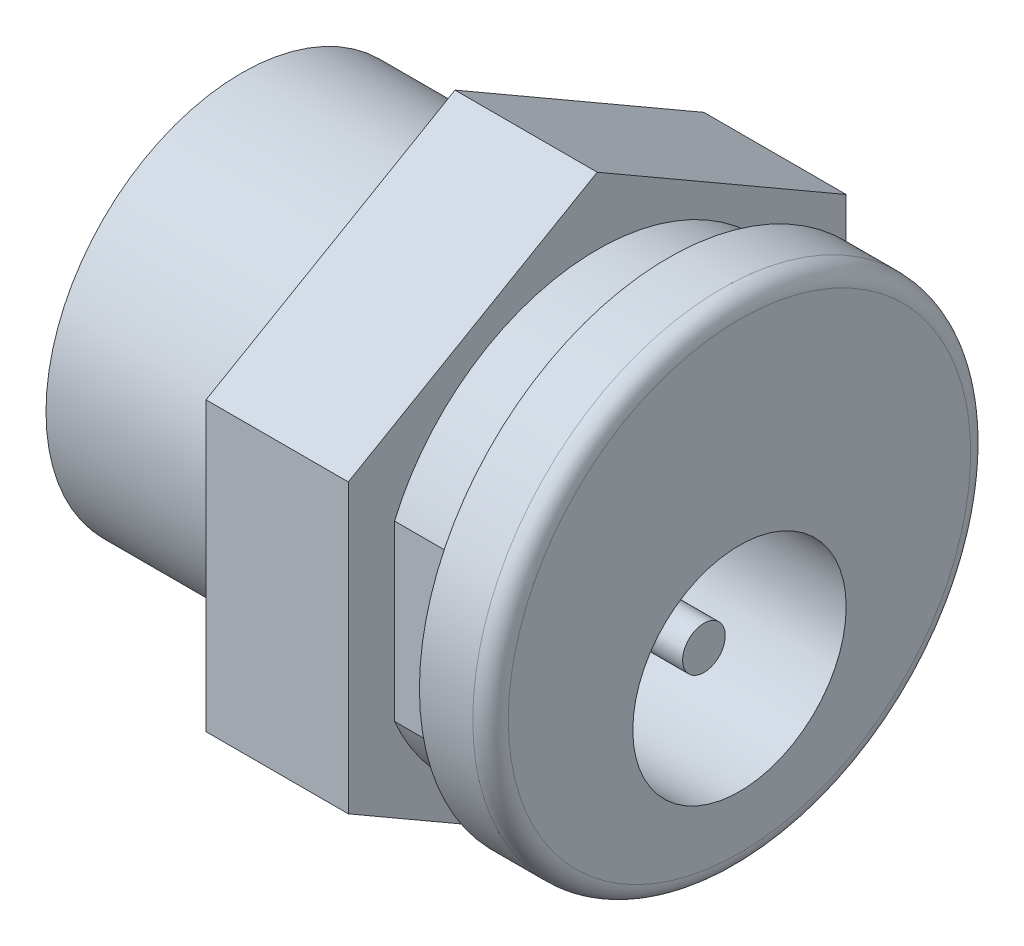
from build123d import *

# Parameters (mm, degrees)
ESQUISSE2_R             = 10
ENL_V_MAT_EXTRU_1_DEPTH = 4
ESQUISSE3_R             = 3
ESQUISSE3_R_2           = 0.6
ENL_V_MAT_EXTRU_2_DEPTH = 9
ESQUISSE4_R             = 0.6
ENL_V_MAT_EXTRU_3_DEPTH = 1
ENL_V_MAT_EXTRU_5_DEPTH = 2
CONG_1_R                = 0.5


with BuildPart() as part:
    # Esquisse1 → Révolution1 (revolve)
    with BuildSketch(Plane.XY, mode=Mode.PRIVATE) as r_volution1_sk:
        Polygon((0, 0), (0, 7), (-2, 7), (-2, 6.2), (-4, 6.2), (-4, 10), (-8, 10), (-8, 5.5), (-14, 5.5), (-14, 0), align=None)
    revolve(r_volution1_sk.sketch.rotate(Axis((0, 0, 0), (1, 0, 0)), 90), axis=Axis((0, 0, 0), (1, 0, 0)))  # turned: the seam where the file's is

    # Esquisse2 → Enlèv. mat.-Extru.1 (cut)
    with BuildSketch(Plane.ZY.offset(8)):
        Circle(ESQUISSE2_R)
        Polygon((0, 8.082903769), (-7, 4.041451884), (-7, -4.041451884), (0, -8.082903769), (7, -4.041451884), (7, 4.041451884), align=None, mode=Mode.SUBTRACT)
    extrude(amount=-ENL_V_MAT_EXTRU_1_DEPTH, mode=Mode.SUBTRACT)

    # Esquisse3 → Enlèv. mat.-Extru.2 (cut)
    with BuildSketch(Plane(origin=(0, 0, 0), x_dir=(0, 0, -1), z_dir=(1, 0, 0))):
        with Locations((0, -2)):
            Circle(ESQUISSE3_R)
        with Locations((0, -2)):
            Circle(ESQUISSE3_R_2, mode=Mode.SUBTRACT)
    extrude(amount=-ENL_V_MAT_EXTRU_2_DEPTH, mode=Mode.SUBTRACT)

    # Esquisse4 → Enlèv. mat.-Extru.3 (cut)
    with BuildSketch(Plane(origin=(0, 0, 0), x_dir=(0, 0, -1), z_dir=(1, 0, 0))):
        with Locations((0, -2)):
            Circle(ESQUISSE4_R)
    extrude(amount=-ENL_V_MAT_EXTRU_3_DEPTH, mode=Mode.SUBTRACT)

    # Esquisse5 → Enlèv. mat.-Extru.5 (cut)
    with BuildSketch(Plane(origin=(-4, 0, 0), x_dir=(0, 0, -1), z_dir=(1, 0, 0))):
        with BuildLine():
            Line((-5.7, 2.439262184), (-5.7, -2.439262184))
            ThreePointArc((-5.7, -2.439262184), (-6.2, 0), (-5.7, 2.439262184))
        make_face()
        with BuildLine():
            Line((5.7, 2.439262184), (5.7, -2.439262184))
            ThreePointArc((5.7, -2.439262184), (6.2, 0), (5.7, 2.439262184))
        make_face()
    extrude(amount=ENL_V_MAT_EXTRU_5_DEPTH, mode=Mode.SUBTRACT)

    # Congé1
    cong_1_edges = [part.edges().sort_by_distance(p)[0] for p in [
        (0, 0, -7),
    ]]
    fillet(cong_1_edges, radius=CONG_1_R)


solid = part.part
